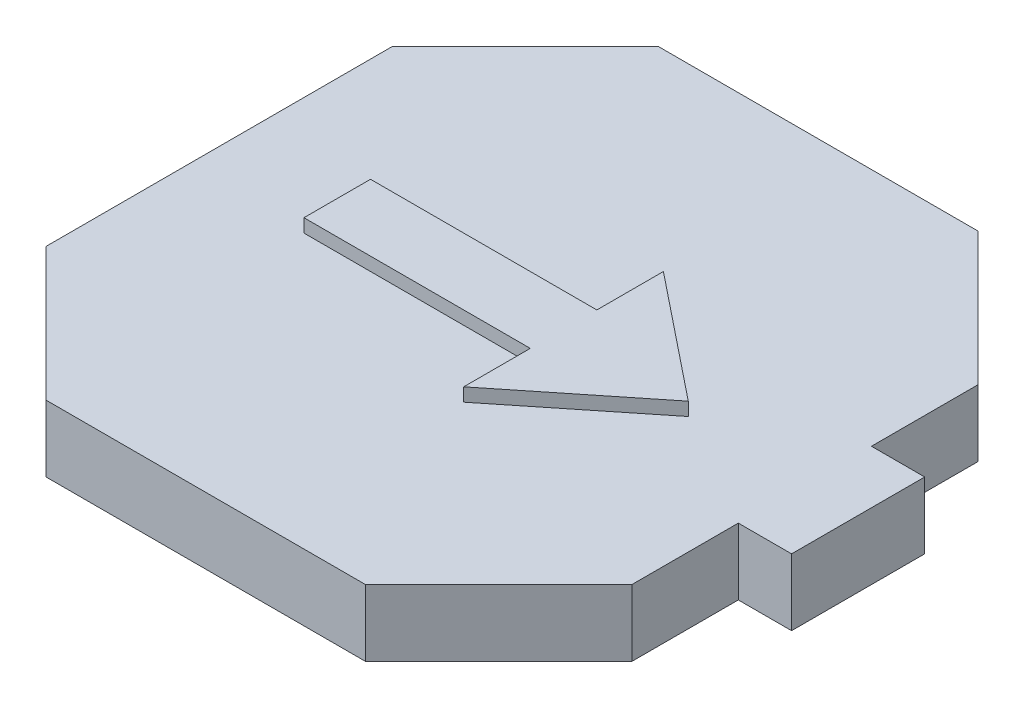
from build123d import *

# Parameters (mm, degrees)
BOSS_EXTRU_1_DEPTH      = 5
BOSS_EXTRU_2_DEPTH      = 1
ESQUISSE3_W             = 5
ESQUISSE3_H             = 5
ENL_V_MAT_EXTRU_1_DEPTH = 4.8


with BuildPart() as part:
    # Esquisse1 → Boss.-Extru.1 (new body)
    with BuildSketch(Plane(origin=(0, 0, 0), x_dir=(1, 0, 0), z_dir=(0, 1, 0))):
        Polygon((22, 13), (12.003020456, 23), (-12.003020456, 23), (-22, 13), (-22, -13), (-12.003020456, -23), (12.003020456, -23), (22, -13), (22, -5), (26, -5), (26, 5), (22, 5), align=None)
    extrude(amount=BOSS_EXTRU_1_DEPTH)

    # Esquisse2 → Boss.-Extru.2 (add)
    with BuildSketch(Plane(origin=(0, 5, 0), x_dir=(1, 0, 0), z_dir=(0, 1, 0))):
        Polygon((3.82, 2.552581319), (3.82, 7.552581319), (13.187496998, 0.052581319), (3.82, -7.447418681), (3.82, -2.447418681), (-13.18, -2.447418681), (-13.18, 2.552581319), align=None)
    extrude(amount=BOSS_EXTRU_2_DEPTH)

    # Esquisse3 → Enlèv. mat.-Extru.1 (cut)
    with BuildSketch(Plane.XZ):
        with Locations((-13.5, 14.5)):
            Rectangle(ESQUISSE3_W, ESQUISSE3_H)
        with Locations((-13.5, -14.5)):
            Rectangle(ESQUISSE3_W, ESQUISSE3_H)
        with Locations((14.5, -14.5)):
            Rectangle(ESQUISSE3_W, ESQUISSE3_H)
        with Locations((13.5, 14.5)):
            Rectangle(ESQUISSE3_W, ESQUISSE3_H)
        Rectangle(ESQUISSE3_W, ESQUISSE3_H)
    extrude(amount=-ENL_V_MAT_EXTRU_1_DEPTH, mode=Mode.SUBTRACT)


solid = part.part
